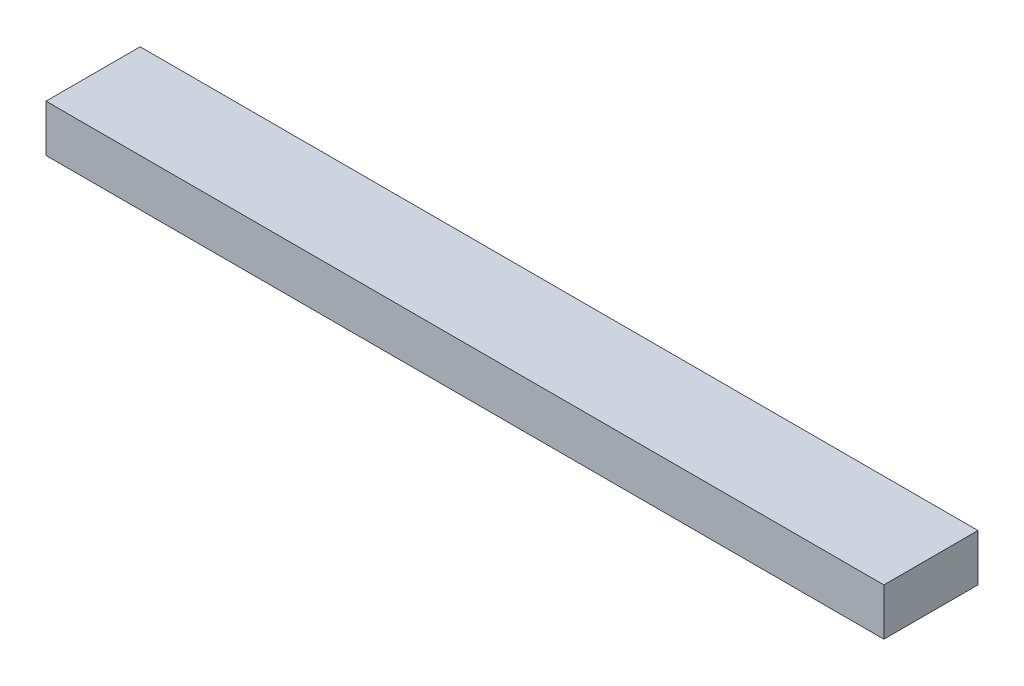
from build123d import *

# Parameters (mm, degrees)
SKETCH_1_W      = 200
SKETCH_1_H      = 100
EXTRUDE_1_DEPTH = 1780


with BuildPart() as part:
    # 草图1 → 凸台-拉伸1 (new body)
    with BuildSketch(Plane(origin=(0, 0, 0), x_dir=(0, 0, -1), z_dir=(1, 0, 0))):
        Rectangle(SKETCH_1_W, SKETCH_1_H)
    extrude(amount=-EXTRUDE_1_DEPTH)


solid = part.part
